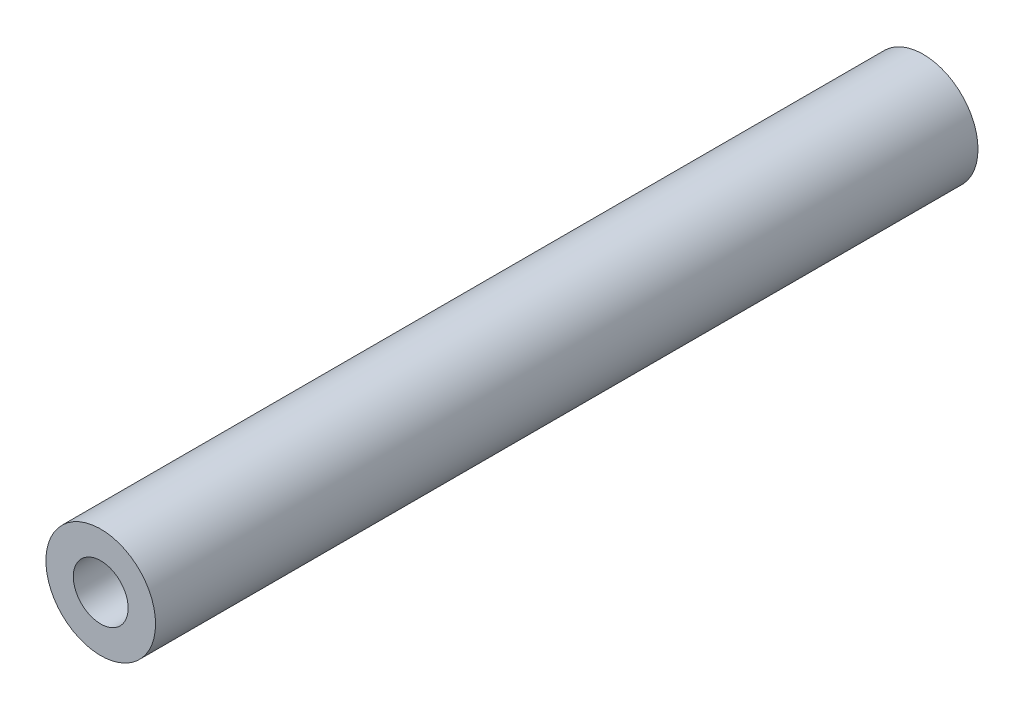
from build123d import *

# Parameters (mm, degrees)
SKETCH1_R           = 2
SKETCH1_R_2         = 1
BOSS_EXTRUDE1_DEPTH = 30


with BuildPart() as part:
    # Sketch1 → Boss-Extrude1 (new body)
    with BuildSketch(Plane.XY):
        Circle(SKETCH1_R)
        Circle(SKETCH1_R_2, mode=Mode.SUBTRACT)
    extrude(amount=BOSS_EXTRUDE1_DEPTH)


solid = part.part
